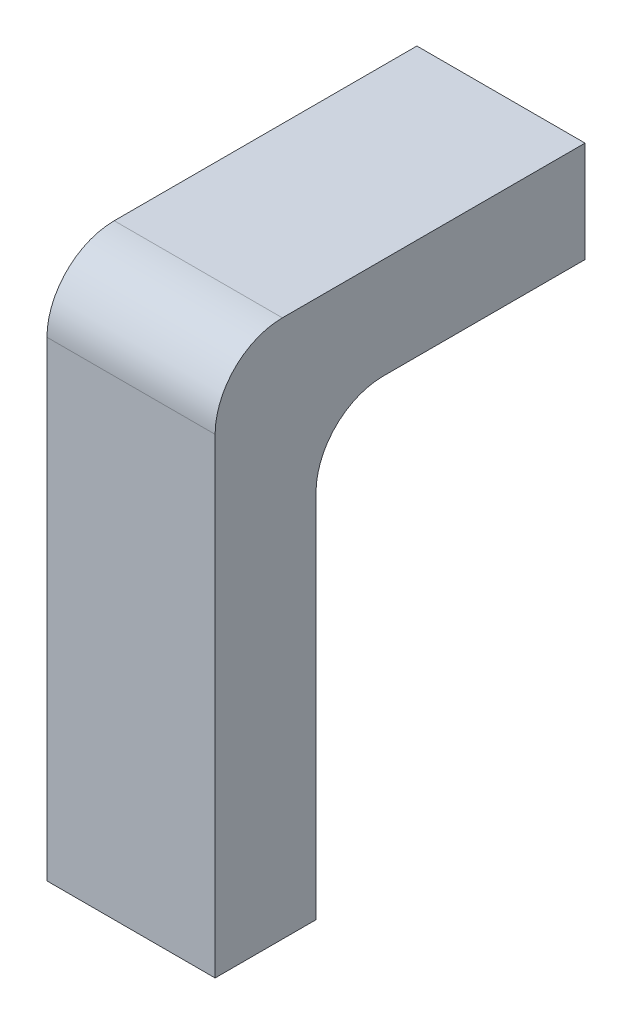
from build123d import *

# Parameters (mm, degrees)
SKETCH_1_W          = 2.5
SKETCH_1_H          = 1.5
EXTRUDE_1_DEPTH     = 8
SKETCH_5_R          = 0.435
CUT_EXTRUDE_1_DEPTH = 3
SKETCH_6_W          = 2.5
SKETCH_6_H          = 1.5
EXTRUDE_2_DEPTH     = 4
FILLET_1_R          = 1
SKETCH_7_R          = 0.435
CUT_EXTRUDE_2_DEPTH = 2


with BuildPart() as part:
    # Эскиз1 → Бобышка-Вытянуть1 (new body)
    with BuildSketch(Plane(origin=(0, 0, 0), x_dir=(1, 0, 0), z_dir=(0, 1, 0))):
        Rectangle(SKETCH_1_W, SKETCH_1_H)
    extrude(amount=EXTRUDE_1_DEPTH)

    # Эскиз5 → Вырез-Вытянуть1 (cut)
    with BuildSketch(Plane.XZ):
        with Locations((0.535, 0)):
            Circle(SKETCH_5_R)
        with Locations((-0.535, 0)):
            Circle(SKETCH_5_R)
    extrude(amount=-CUT_EXTRUDE_1_DEPTH, mode=Mode.SUBTRACT)

    # Эскиз6 → Бобышка-Вытянуть2 (add)
    with BuildSketch(Plane(origin=(0, 0, -0.75), x_dir=(-1, 0, 0), z_dir=(0, 0, -1))):
        with Locations((0, 7.25)):
            Rectangle(SKETCH_6_W, SKETCH_6_H)
    extrude(amount=EXTRUDE_2_DEPTH)

    # Скругление1
    fillet_1_edges = [part.edges().sort_by_distance(p)[0] for p in [
        (0, 8, 0.75),
        (0, 6.5, -0.75),
    ]]
    fillet(fillet_1_edges, radius=FILLET_1_R)

    # Эскиз7 → Вырез-Вытянуть2 (cut)
    with BuildSketch(Plane(origin=(0, 0, -4.75), x_dir=(-1, 0, 0), z_dir=(0, 0, -1))):
        with Locations((-0.535, 7.25)):
            Circle(SKETCH_7_R)
        with Locations((0.535, 7.25)):
            Circle(SKETCH_7_R)
    extrude(amount=-CUT_EXTRUDE_2_DEPTH, mode=Mode.SUBTRACT)


solid = part.part
